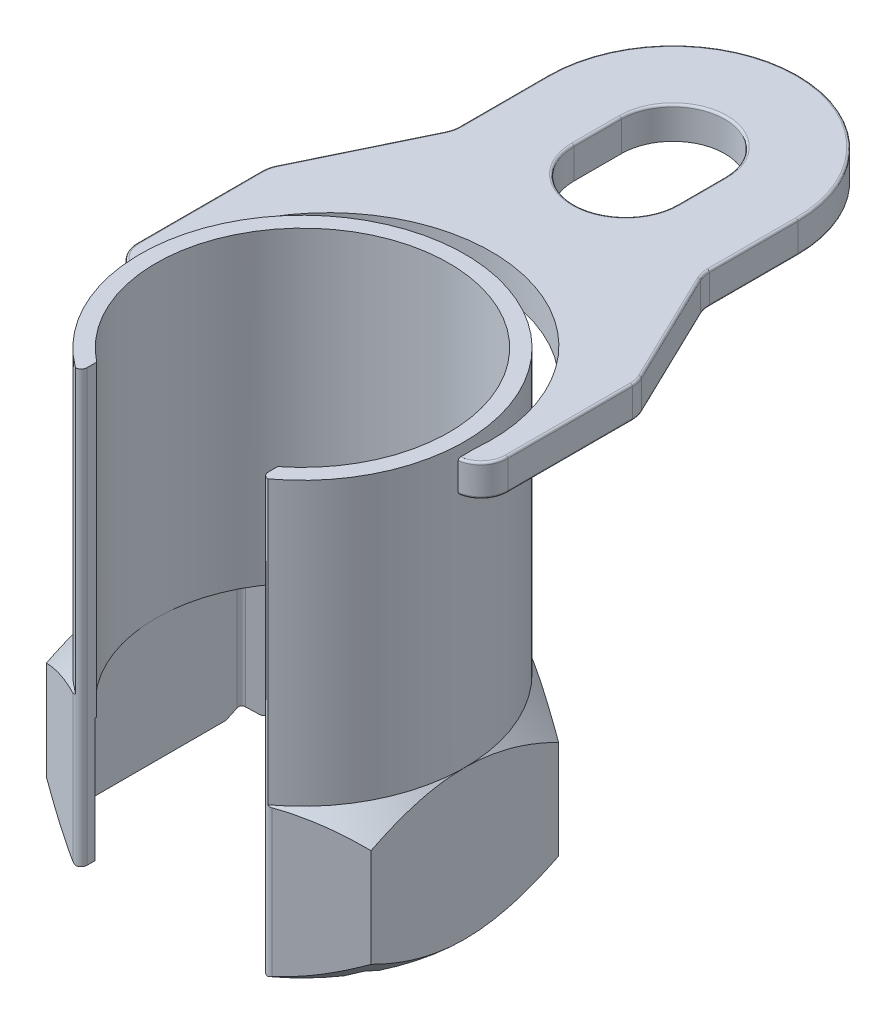
from build123d import *
from build123d.topology import SkipClean

# Parameters (mm, degrees)
EXTRUDE1_DEPTH     = 34.5
EXTRUDE2_DEPTH     = 65.5
SKETCH8_OUTSIDE_W  = 308.522
SKETCH8_OUTSIDE_H  = 308.054
SKETCH8_OUTSIDE_R  = 37.672105065
CUT_EXTRUDE4_DEPTH = 101
CUT_EXTRUDE4_DRAFT = -45
SKETCH19_OUTSIDE_W = 177.522
SKETCH19_OUTSIDE_H = 177.054
SKETCH19_OUTSIDE_R = 37.672005065
CUT_EXTRUDE6_DEPTH = 35.5
CUT_EXTRUDE6_DRAFT = -45
CUT_EXTRUDE9_START = -28.672005
CUT_EXTRUDE9_DEPTH = 28.672029
FILLET1_R          = 1.4
EXTRUDE7_DEPTH     = 7.4
CUT_EXTRUDE8_REACH = 99.4
FILLET4_R          = 0.5


with BuildPart() as part:
    # Sketch1 → Extrude1 (new body)
    with BuildSketch(Plane(origin=(0, 0, 0), x_dir=(1, 0, 0), z_dir=(0, 1, 0))):
        with BuildLine():
            Line((-21, -26.739483914), (-21, -31.375644347))
            Line((-21, -31.375644347), (-37.672105065, -21.75))
            Line((-37.672105065, -21.75), (-37.672105065, 21.75))
            Line((-37.672105065, 21.75), (0, 43.5))
            Line((0, 43.5), (37.672105065, 21.75))
            Line((37.672105065, 21.75), (37.672105065, -21.75))
            Line((37.672105065, -21.75), (21, -31.375644347))
            Line((21, -31.375644347), (21, -26.739483914))
            ThreePointArc((21, -26.739483914), (0, 34), (-21, -26.739483914))
        make_face()
    extrude(amount=EXTRUDE1_DEPTH)

    # Sketch3 → Extrude2 (add)
    with BuildSketch(Plane(origin=(0, 34.5, 0), x_dir=(-1, 0, 0), z_dir=(0, 1, 0))):
        with BuildLine():
            Line((-21, 31.275868742), (-21, 26.739483914))
            ThreePointArc((-21, 26.739483914), (0, -34), (21, 26.739483914))
            Line((21, 26.739483914), (21, 31.275868742))
            ThreePointArc((21, 31.275868742), (0, -37.672005065), (-21, 31.275868742))
        make_face()
    extrude(amount=EXTRUDE2_DEPTH)


with BuildPart() as cut_extrude4_tool:
    # Sketch8 outside → Cut-Extrude4 (with draft: the straight prism first)
    with BuildSketch(Plane.XZ):
        with Locations((0, -6.062)):
            Rectangle(SKETCH8_OUTSIDE_W, SKETCH8_OUTSIDE_H)
        Circle(SKETCH8_OUTSIDE_R, mode=Mode.SUBTRACT)
    extrude(amount=-CUT_EXTRUDE4_DEPTH)
    # Cut-Extrude4: the draft: its side faces are tilted about the plane it starts from
    cut_extrude4_sides = [cut_extrude4_tool.faces().sort_by_distance(p)[0] for p in [
        (0, 50.5, -160.089),
        (154.261, 50.5, -6.062),
        (0, 50.5, 147.965),
        (-154.261, 50.5, -6.062),
        (-37.672105065, 50.5, 0),
    ]]
    draft(cut_extrude4_sides, Plane.XZ, CUT_EXTRUDE4_DRAFT)


with BuildPart() as part_1:
    add(part.part)

    # Cut-Extrude4: cut by cut_extrude4_tool
    add(cut_extrude4_tool.part, mode=Mode.SUBTRACT)


with BuildPart() as cut_extrude6_tool:
    # Sketch19 outside → Cut-Extrude6 (with draft: the straight prism first)
    with BuildSketch(Plane(origin=(0, 34.5, 0), x_dir=(-1, 0, 0), z_dir=(0, 1, 0))):
        with Locations((0, -6.062)):
            Rectangle(SKETCH19_OUTSIDE_W, SKETCH19_OUTSIDE_H)
        Circle(SKETCH19_OUTSIDE_R, mode=Mode.SUBTRACT)
    extrude(amount=-CUT_EXTRUDE6_DEPTH)
    # Cut-Extrude6: the draft: its side faces are tilted about the plane it starts from
    cut_extrude6_sides = [cut_extrude6_tool.faces().sort_by_distance(p)[0] for p in [
        (0, 16.75, -94.589),
        (-88.761, 16.75, -6.062),
        (0, 16.75, 82.465),
        (88.761, 16.75, -6.062),
        (37.672005065, 16.75, 0),
    ]]
    draft(cut_extrude6_sides, Plane(origin=(0, 34.5, 0), x_dir=(-1, 0, 0), z_dir=(0, 1, 0)), CUT_EXTRUDE6_DRAFT)


with BuildPart() as part_2:
    add(part_1.part)

    # Cut-Extrude6: cut by cut_extrude6_tool
    add(cut_extrude6_tool.part, mode=Mode.SUBTRACT)

    # Sketch26 → Cut-Extrude9 (cut)
    with BuildSketch(Plane.XZ.offset(CUT_EXTRUDE9_START)):
        Polygon((-34, -19.629909152), (0, -39.259818305), (34, -19.629909152), (34, 19.629909152), (0, 39.259818305), (-34, 19.629909152), align=None)
    extrude(amount=CUT_EXTRUDE9_DEPTH, mode=Mode.SUBTRACT)

    # Fillet1
    fillet1_edges = [part_2.edges().sort_by_distance(p)[0] for p in [
        (-34, 15.12985912, -19.629909152),
        (-34, 15.12985912, 19.629909152),
        (34, 15.12985912, 19.629909152),
        (34, 15.12985912, -19.629909152),
        (-21, 17.24995, 31.375644347),
        (21, 17.24995, 31.375644347),
        (0, 15.12985912, -39.259818305),
    ]]
    fillet(fillet1_edges, radius=FILLET1_R)

    # Sketch16 → Extrude7 (add)
    with BuildSketch(Plane(origin=(0, 90, 0), x_dir=(-1, 0, 0), z_dir=(0, 1, 0))):
        with BuildLine():
            Line((-29, -86), (-29, -65.418243081))
            ThreePointArc((-29, -65.418243081), (-29.156110321, -64.035710062), (-29.616579855, -62.722798873))
            Line((-29.616579855, -62.722798873), (-42.383420145, -36.277201127))
            ThreePointArc((-42.383420145, -36.277201127), (-42.843889679, -34.964289938), (-43, -33.581756919))
            Line((-43, -33.581756919), (-43, -4.642541553))
            ThreePointArc((-43, -4.642541553), (-41.472323148, -0.567078832), (-37.642130195, 1.5))
            ThreePointArc((-37.642130195, 1.5), (0, -37.672005065), (37.642130195, 1.5))
            ThreePointArc((37.642130195, 1.5), (41.472323148, -0.567078832), (43, -4.642541553))
            Line((43, -4.642541553), (43, -33.581756919))
            ThreePointArc((43, -33.581756919), (42.843889679, -34.964289938), (42.383420145, -36.277201127))
            Line((42.383420145, -36.277201127), (29.616579855, -62.722798873))
            ThreePointArc((29.616579855, -62.722798873), (29.156110321, -64.035710062), (29, -65.418243081))
            Line((29, -65.418243081), (29, -86))
            ThreePointArc((29, -86), (0, -115), (-29, -86))
        make_face()
    extrude(amount=EXTRUDE7_DEPTH)

    # Sketch25 → Cut-Extrude8 (cut, up to next)
    with BuildSketch(Plane.XZ.offset(-97.4), mode=Mode.PRIVATE) as cut_extrude8_sk1:
        with BuildLine():
            Line((-12, -86), (-12, -75))
            ThreePointArc((-12, -75), (0, -63), (12, -75))
            Line((12, -75), (12, -86))
            ThreePointArc((12, -86), (0, -98), (-12, -86))
        make_face()
    cut_extrude8_tool1 = extrude(cut_extrude8_sk1.sketch, amount=CUT_EXTRUDE8_REACH, mode=Mode.PRIVATE) & part_2.part
    add(cut_extrude8_tool1.solids().sort_by_distance((0, 97.4, -80.5))[0], mode=Mode.SUBTRACT)
    # Sketch25 → Cut-Extrude8 (cut, up to next)
    with BuildSketch(Plane.XZ.offset(-97.4), mode=Mode.PRIVATE) as cut_extrude8_sk2:
        with BuildLine():
            ThreePointArc((37.618877782, -2), (0, -37.672005065), (-37.618877782, -2))
            ThreePointArc((-37.618877782, -2), (0, -43.830939264), (37.618877782, -2))
        make_face()
    cut_extrude8_tool2 = extrude(cut_extrude8_sk2.sketch, amount=CUT_EXTRUDE8_REACH, mode=Mode.PRIVATE) & part_2.part
    add(cut_extrude8_tool2.solids().sort_by_distance((0, 97.4, -38.53656))[0], mode=Mode.SUBTRACT)

    # Fillet4
    fillet4_edges = [part_2.edges().sort_by_distance(p)[0] for p in [
        (-41.472323148, 90, -0.567078832),
        (41.472323148, 90, -0.567078832),
        (43, 90, -19.112149236),
        (42.843889679, 90, -34.964289938),
        (36, 90, -49.5),
        (29.156110321, 90, -64.035710062),
        (29, 90, -75.70912154),
        (0, 90, -115),
        (-29, 90, -75.70912154),
        (-29.156110321, 90, -64.035710062),
        (-36, 90, -49.5),
        (-42.843889679, 90, -34.964289938),
        (-43, 90, -19.112149236),
        (-41.472323148, 97.4, -0.567078832),
        (41.472323148, 97.4, -0.567078832),
        (43, 97.4, -19.112149236),
        (42.843889679, 97.4, -34.964289938),
        (36, 97.4, -49.5),
        (29.156110321, 97.4, -64.035710062),
        (29, 97.4, -75.70912154),
        (0, 97.4, -115),
        (-29, 97.4, -75.70912154),
        (-29.156110321, 97.4, -64.035710062),
        (-36, 97.4, -49.5),
        (-42.843889679, 97.4, -34.964289938),
        (-43, 97.4, -19.112149236),
        (0, 97.4, -98),
        (12, 97.4, -80.5),
        (0, 97.4, -63),
        (-12, 97.4, -80.5),
    ]]
    fillet(fillet4_edges, radius=FILLET4_R)


solid = part_2.part
